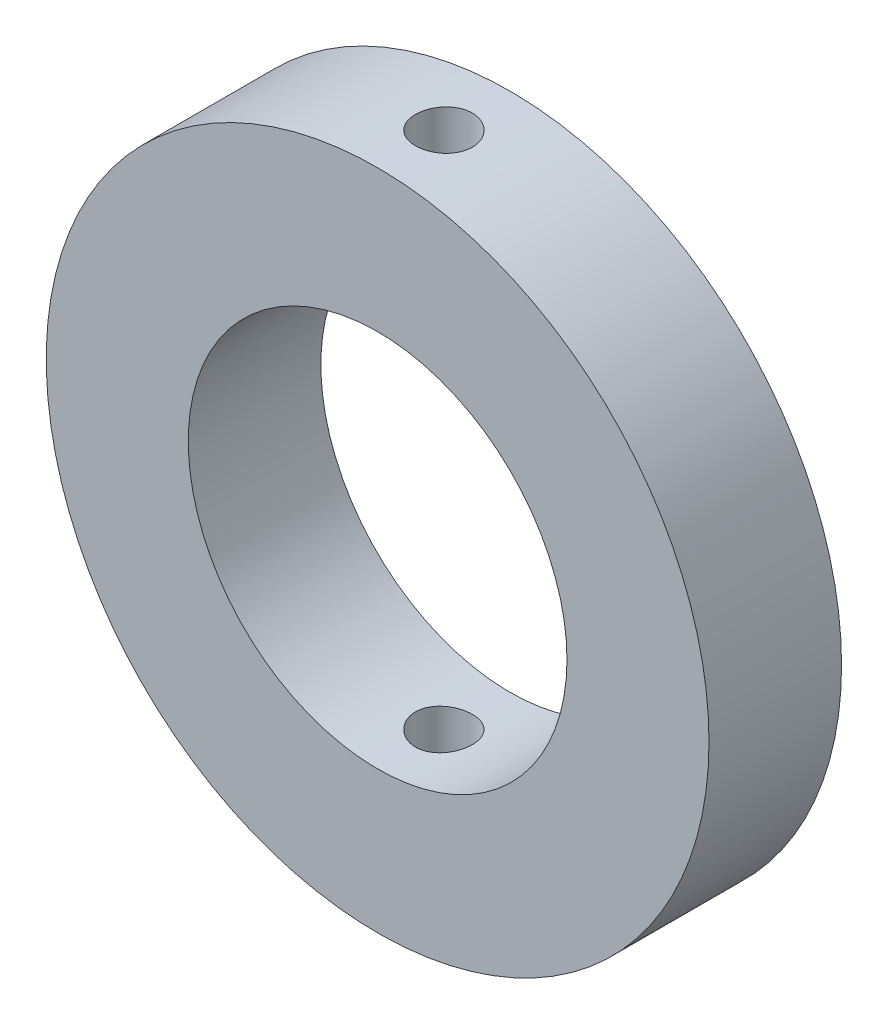
from build123d import *

# Parameters (mm, degrees)
SKETCH2_R               = 17.5
SKETCH2_R_2             = 10
BOSS_EXTRUDE1_DEPTH     = 7
SKETCH3_R               = 1.5
CUT_EXTRUDE1_DEPTH      = 18.5
CUT_EXTRUDE1_DEPTH_BACK = 18.5


with BuildPart() as part:
    # Sketch2 → Boss-Extrude1 (new body)
    with BuildSketch(Plane.XY):
        Circle(SKETCH2_R)
        Circle(SKETCH2_R_2, mode=Mode.SUBTRACT)
    extrude(amount=BOSS_EXTRUDE1_DEPTH)

    # Sketch3 → Cut-Extrude1 (cut, two sides)
    with BuildSketch(Plane(origin=(0, 0, 0), x_dir=(1, 0, 0), z_dir=(0, 1, 0))) as cut_extrude1_sk:
        with Locations((0, -3.5)):
            Circle(SKETCH3_R)
    extrude(amount=CUT_EXTRUDE1_DEPTH, mode=Mode.SUBTRACT)
    extrude(cut_extrude1_sk.sketch, amount=-CUT_EXTRUDE1_DEPTH_BACK, mode=Mode.SUBTRACT)


solid = part.part
